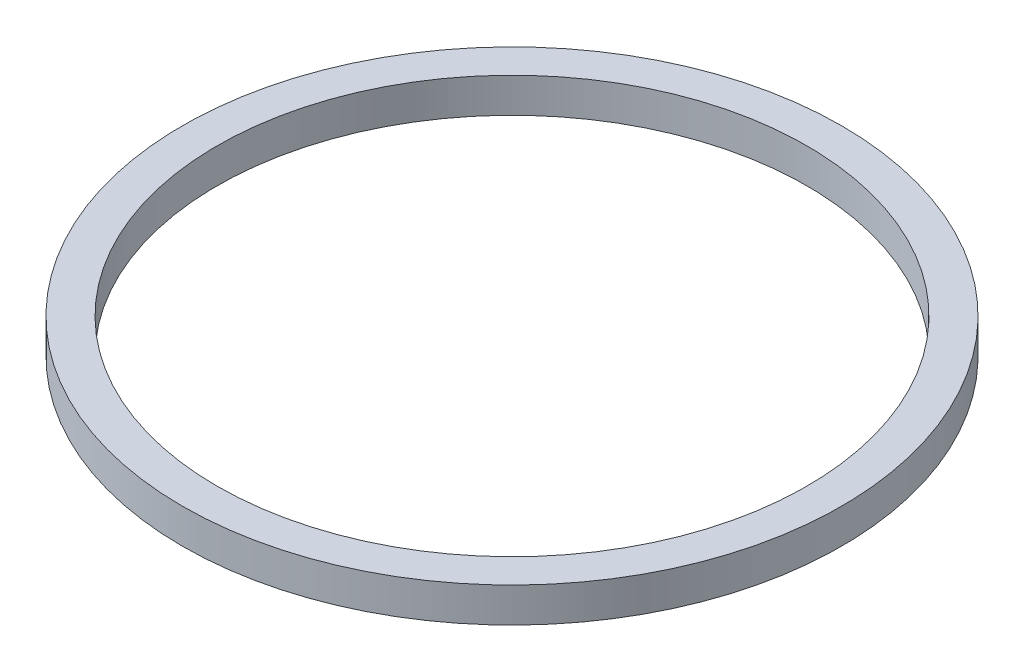
from build123d import *

# Parameters (mm, degrees)
SKETCH2_R           = 9.5
SKETCH2_R_2         = 8.5
BOSS_EXTRUDE1_DEPTH = 1


with BuildPart() as part:
    # Sketch2 → Boss-Extrude1 (new body)
    with BuildSketch(Plane(origin=(0, 0, 0), x_dir=(1, 0, 0), z_dir=(0, 1, 0))):
        Circle(SKETCH2_R)
        Circle(SKETCH2_R_2, mode=Mode.SUBTRACT)
    extrude(amount=BOSS_EXTRUDE1_DEPTH)


solid = part.part
